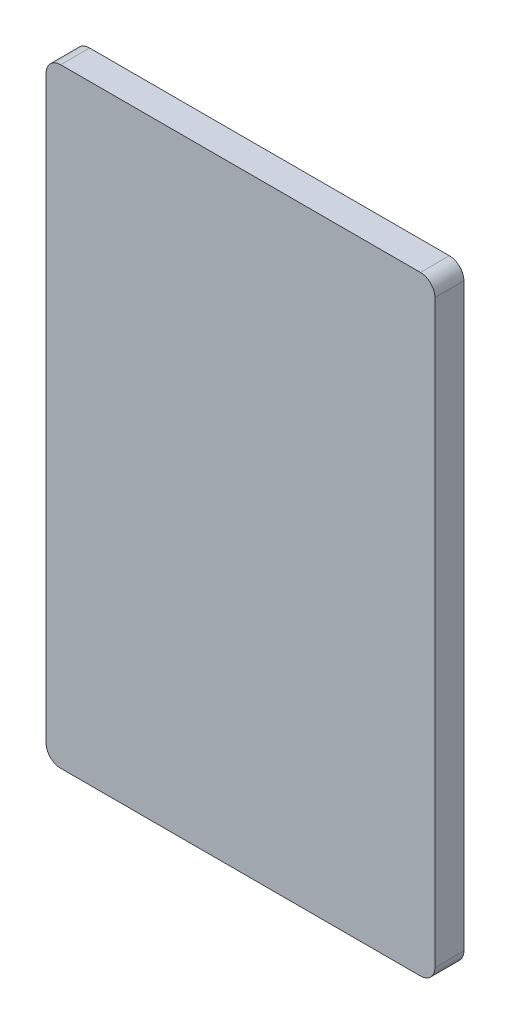
from build123d import *

# Parameters (mm, degrees)
EXTRUDE_2_DEPTH = 5


with BuildPart() as part:
    # 草图2 → 凸台-拉伸2 (new body)
    with BuildSketch(Plane.XY):
        with BuildLine():
            Line((2.5, 0), (64.658583814, 0))
            ThreePointArc((64.658583814, 0), (66.426350767, 0.732233047), (67.158583814, 2.5))
            Line((67.158583814, 2.5), (67.158583814, 102.7498))
            ThreePointArc((67.158583814, 102.7498), (66.426350767, 104.517566953), (64.658583814, 105.2498))
            Line((64.658583814, 105.2498), (2.5, 105.2498))
            ThreePointArc((2.5, 105.2498), (0.732233047, 104.517566953), (0, 102.7498))
            Line((0, 102.7498), (0, 2.5))
            ThreePointArc((0, 2.5), (0.732233047, 0.732233047), (2.5, 0))
        make_face()
    extrude(amount=EXTRUDE_2_DEPTH)


solid = part.part
